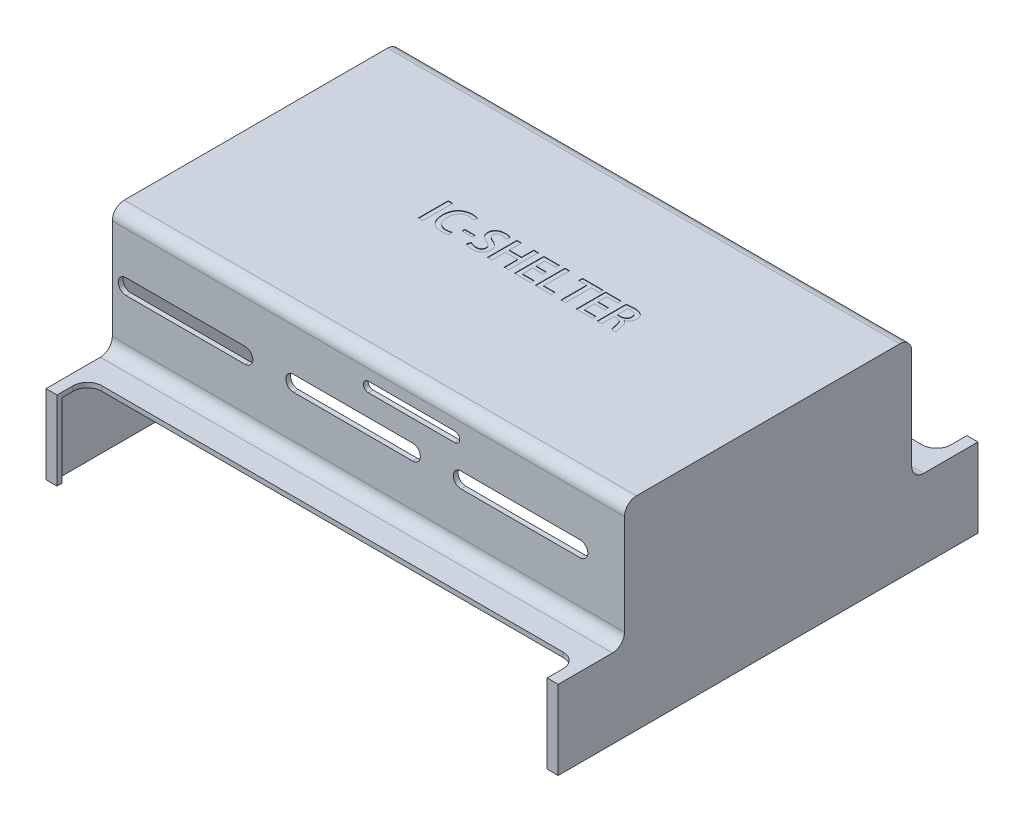
from build123d import *

# Parameters (mm, degrees)
BOSS_EXTRUDE1_DEPTH = 53.5
SHELL4_T            = -1
FILLET2_R           = 2.5
FILLET3_R           = 2.5
FILLET4_R           = 2.5
FILLET5_R           = 2.5
CUT_EXTRUDE9_DEPTH  = 74.85
LPATTERN4_COUNT     = 3
LPATTERN4_PITCH     = 35
SKETCH17_W          = 105
SKETCH17_H          = 58
BOSS_EXTRUDE2_DEPTH = 2
CUT_EXTRUDE8_DEPTH  = 74.85
CUT_EXTRUDE15_DEPTH = 17.5
SKETCH21_W          = 0.952687977
SKETCH21_H          = 6.208888889
SKETCH21_W_2        = 2.23016722
SKETCH21_H_2        = 0.591324006
CUT_EXTRUDE17_DEPTH = 0.1


with BuildPart() as part:
    # Sketch1 → Boss-Extrude1 (new body, symmetric)
    with BuildSketch(Plane(origin=(0, 0, 0), x_dir=(0, 0, -1), z_dir=(1, 0, 0))):
        Polygon((-43.85, 0), (-43.85, 16.5), (-30, 16.5), (-30, 42.428582774), (30, 42.428582774), (30, 16.5), (43.85, 16.5), (43.85, 0), align=None)
    extrude(amount=BOSS_EXTRUDE1_DEPTH, both=True)

    # Shell4
    shell4_openings = [part.faces().sort_by_distance(p)[0] for p in [
        (0, 0, 0),
    ]]
    offset(amount=SHELL4_T, openings=shell4_openings, kind=Kind.INTERSECTION)

    # Fillet2
    fillet2_edges = [part.edges().sort_by_distance(p)[0] for p in [
        (0, 42.428582774, 30),
    ]]
    fillet(fillet2_edges, radius=FILLET2_R)

    # Fillet3
    fillet3_edges = [part.edges().sort_by_distance(p)[0] for p in [
        (0, 16.5, 30),
    ]]
    fillet(fillet3_edges, radius=FILLET3_R)

    # Fillet4
    fillet4_edges = [part.edges().sort_by_distance(p)[0] for p in [
        (0, 42.428582774, -30),
    ]]
    fillet(fillet4_edges, radius=FILLET4_R)

    # Fillet5
    fillet5_edges = [part.edges().sort_by_distance(p)[0] for p in [
        (0, 16.5, -30),
    ]]
    fillet(fillet5_edges, radius=FILLET5_R)

    # Sketch16 → Cut-Extrude9 (cut, through all)
    with BuildSketch(Plane.XY.offset(30)):
        with BuildLine():
            Line((-50.64618597, 31.08095788), (-25.769711707, 31.08095788))
            ThreePointArc((-25.769711707, 31.08095788), (-24.153045214, 29.464291387), (-25.769711707, 27.847624894))
            Line((-25.769711707, 27.847624894), (-50.64618597, 27.847624894))
            ThreePointArc((-50.64618597, 27.847624894), (-52.262852463, 29.464291387), (-50.64618597, 31.08095788))
        make_face()
    cut_extrude9 = extrude(amount=-CUT_EXTRUDE9_DEPTH, mode=Mode.SUBTRACT)

    # LPattern4: Cut-Extrude9 ×3
    with Locations(*[(i * LPATTERN4_PITCH, 0, 0) for i in range(1, LPATTERN4_COUNT)]):
        add(cut_extrude9, mode=Mode.SUBTRACT)

    # Sketch17 → Boss-Extrude2 (add)
    with BuildSketch(Plane.XZ.offset(-41.428582774)):
        Rectangle(SKETCH17_W, SKETCH17_H)
    extrude(amount=BOSS_EXTRUDE2_DEPTH)

    # Sketch15 → Cut-Extrude8 (cut, through all)
    with BuildSketch(Plane(origin=(0, 0, -30), x_dir=(-1, 0, 0), z_dir=(0, 0, -1))):
        with BuildLine():
            Line((0, 37.667214373), (-18.032020922, 37.667214373))
            ThreePointArc((-18.032020922, 37.667214373), (-19.077355469, 36.621879827), (-18.032020922, 35.57654528))
            Line((-18.032020922, 35.57654528), (0, 35.57654528))
            ThreePointArc((0, 35.57654528), (1.045334546, 36.621879827), (0, 37.667214373))
        make_face()
    extrude(amount=-CUT_EXTRUDE8_DEPTH, mode=Mode.SUBTRACT)

    # Sketch19 → Cut-Extrude15 (cut, through all)
    with BuildSketch(Plane(origin=(0, 16.5, 0), x_dir=(1, 0, 0), z_dir=(0, 1, 0))):
        with BuildLine():
            Line((-48.19, -37.5), (48.19, -37.5))
            ThreePointArc((48.19, -37.5), (50.311320344, -38.378679656), (51.19, -40.5))
            Line((51.19, -40.5), (51.19, -43.85))
            Line((51.19, -43.85), (-51.19, -43.85))
            Line((-51.19, -43.85), (-51.19, -40.5))
            ThreePointArc((-51.19, -40.5), (-50.311320344, -38.378679656), (-48.19, -37.5))
        make_face()
    cut_extrude15 = extrude(amount=-CUT_EXTRUDE15_DEPTH, mode=Mode.SUBTRACT)

    # Mirror3: Cut-Extrude15 across plane
    add(cut_extrude15.mirror(Plane.XY), mode=Mode.SUBTRACT)

    # Sketch21 → Cut-Extrude17 (cut)
    with BuildSketch(Plane(origin=(0, 42.428582774, 0), x_dir=(1, 0, 0), z_dir=(0, 1, 0))):
        with Locations((-19.072509342, 3.116177041)):
            Rectangle(SKETCH21_W, SKETCH21_H)
        with BuildLine():
            add(Edge.make_bspline(
                [(-13.448639907, 0.959167257), (-13.484931771, 0.942766153), (-13.559790632, 0.908935761), (-13.680632958, 0.867309499), (-13.81173933, 0.829651537), (-14.002926186, 0.787850022), (-14.255990468, 0.748993456), (-14.462992266, 0.742472844), (-14.568364996, 0.739153576)],
                knots=[0, 0, 0, 0, 0.000119421, 0.000246328, 0.000382992, 0.000528448, 0.000833254, 0.001149288, 0.001149288, 0.001149288, 0.001149288], degree=3))
            add(Edge.make_bspline(
                [(-14.568364996, 0.739153576), (-14.647064082, 0.741274948), (-14.800721446, 0.745416859), (-15.024772836, 0.774975125), (-15.235473302, 0.824010073), (-15.432960619, 0.892314712), (-15.617241853, 0.979442608), (-15.788379173, 1.085791621), (-15.947001833, 1.210573556), (-16.089981709, 1.356127041), (-16.219668683, 1.517824022), (-16.331561149, 1.698100652), (-16.426760352, 1.894684388), (-16.504023858, 2.108771755), (-16.564698295, 2.339324727), (-16.608632391, 2.586519192), (-16.637588977, 2.850348429), (-16.641729264, 3.032014631), (-16.643861306, 3.125563691)],
                knots=[0, 0, 0, 0, 0.000236061, 0.000460902, 0.000676619, 0.000884034, 0.001086611, 0.00128684, 0.001487299, 0.001690558, 0.001897611, 0.002107912, 0.002325678, 0.002551715, 0.00278963, 0.003040016, 0.00330433, 0.003584938, 0.003584938, 0.003584938, 0.003584938], degree=3))
            add(Edge.make_bspline(
                [(-16.643861306, 3.125563691), (-16.640943543, 3.223813584), (-16.635279976, 3.41452297), (-16.604235026, 3.690926626), (-16.557400874, 3.949079282), (-16.489898056, 4.187334094), (-16.408395866, 4.408140842), (-16.307485436, 4.609366238), (-16.188335309, 4.791778463), (-16.051615132, 4.954078939), (-15.900995778, 5.096659144), (-15.740950975, 5.222927234), (-15.568311996, 5.327379025), (-15.38550063, 5.413603661), (-15.191927611, 5.480569082), (-14.988006165, 5.528777818), (-14.773320171, 5.557236345), (-14.626722929, 5.560671565), (-14.551939361, 5.562423971)],
                knots=[0, 0, 0, 0, 0.000294771, 0.000572169, 0.000833577, 0.00108096, 0.001314129, 0.0015387, 0.001754774, 0.001966286, 0.002173751, 0.002376056, 0.00257667, 0.002777684, 0.002981389, 0.003189986, 0.003405367, 0.003629656, 0.003629656, 0.003629656, 0.003629656], degree=3))
            add(Edge.make_bspline(
                [(-14.551939361, 5.562423971), (-14.495595257, 5.561493678), (-14.385884084, 5.559682247), (-14.22607526, 5.546500742), (-14.075493938, 5.526005166), (-13.934883595, 5.495824676), (-13.803127722, 5.462425921), (-13.681777175, 5.423178834), (-13.569002305, 5.383146396), (-13.499304019, 5.350597529), (-13.465500931, 5.3348116)],
                knots=[0, 0, 0, 0, 0.000169015, 0.000329099, 0.000480754, 0.000624568, 0.000760306, 0.000888321, 0.001007104, 0.001118965, 0.001118965, 0.001118965, 0.001118965], degree=3))
            Line((-13.465500931, 5.3348116), (-13.26211683, 6.072733482))
            add(Edge.make_bspline(
                [(-13.26211683, 6.072733482), (-13.287516924, 6.084472583), (-13.345719737, 6.111372038), (-13.448005369, 6.146675398), (-13.575528755, 6.182379663), (-13.727350945, 6.220252334), (-13.905267656, 6.254675462), (-14.109071611, 6.279507243), (-14.338541368, 6.295879506), (-14.499894256, 6.298844333), (-14.584790631, 6.300404287)],
                knots=[0, 0, 0, 0, 8.3906e-05, 0.000192266, 0.000324095, 0.000481171, 0.000661571, 0.000867344, 0.001096718, 0.001351413, 0.001351413, 0.001351413, 0.001351413], degree=3))
            add(Edge.make_bspline(
                [(-14.584790631, 6.300404287), (-14.692070043, 6.298039653), (-14.902269638, 6.293406471), (-15.210163122, 6.253671989), (-15.502793439, 6.189611606), (-15.780864215, 6.100197426), (-16.043314754, 5.984718225), (-16.291421401, 5.844633185), (-16.523606253, 5.677974436), (-16.739807675, 5.486844957), (-16.936295284, 5.270792944), (-17.109250661, 5.029556216), (-17.254558948, 4.762783315), (-17.374154905, 4.472199149), (-17.469310143, 4.157847942), (-17.538865341, 3.819367045), (-17.583762903, 3.456386387), (-17.592976856, 3.206258427), (-17.597721396, 3.077460046)],
                knots=[0, 0, 0, 0, 0.000321732, 0.000630391, 0.000929574, 0.00121935, 0.001505137, 0.001788331, 0.002072565, 0.00236097, 0.002652508, 0.002946834, 0.003249281, 0.003561729, 0.003887965, 0.004233119, 0.004597223, 0.00498374, 0.00498374, 0.00498374, 0.00498374], degree=3))
            add(Edge.make_bspline(
                [(-17.597721396, 3.077460046), (-17.594607757, 2.95570403), (-17.588553518, 2.718958541), (-17.547006002, 2.374790653), (-17.486574273, 2.051873889), (-17.400449442, 1.750238073), (-17.291560154, 1.470402896), (-17.160047896, 1.210830042), (-17.002834037, 0.974228859), (-16.824503049, 0.758378197), (-16.624345002, 0.567471026), (-16.407607878, 0.399150093), (-16.172672674, 0.257923536), (-15.920693867, 0.142351461), (-15.651616968, 0.051983291), (-15.365195294, -0.013546689), (-15.061472706, -0.053743054), (-14.853199323, -0.060103606), (-14.746700462, -0.063356021)],
                knots=[0, 0, 0, 0, 0.000365202, 0.000710109, 0.001038693, 0.001349892, 0.001649689, 0.001938285, 0.002221062, 0.002500172, 0.002776497, 0.003049188, 0.003321832, 0.003596918, 0.003879264, 0.004171839, 0.004477157, 0.004796648, 0.004796648, 0.004796648, 0.004796648], degree=3))
            add(Edge.make_bspline(
                [(-14.746700462, -0.063356021), (-14.664535645, -0.06229573), (-14.505900216, -0.06024863), (-14.276198, -0.042744618), (-14.063019774, -0.019303427), (-13.867232787, 0.014632151), (-13.691420521, 0.05590092), (-13.536032251, 0.098543787), (-13.402696754, 0.144399673), (-13.323676458, 0.18125297), (-13.287165465, 0.19828088)],
                knots=[0, 0, 0, 0, 0.000246454, 0.000475829, 0.000690779, 0.000889646, 0.001071505, 0.001232344, 0.001372983, 0.001493778, 0.001493778, 0.001493778, 0.001493778], degree=3))
            Line((-13.287165465, 0.19828088), (-13.448639907, 0.959167257))
        make_face()
        with Locations((-11.52610274, 2.477923795)):
            Rectangle(SKETCH21_W_2, SKETCH21_H_2)
        with BuildLine():
            add(Edge.make_bspline(
                [(-6.36450849, 6.034694205), (-6.400841142, 6.05133698), (-6.477467403, 6.086436912), (-6.603017076, 6.133215137), (-6.744432258, 6.177279263), (-6.901641854, 6.218385532), (-7.074125694, 6.254026059), (-7.26191422, 6.279032433), (-7.464769546, 6.295762964), (-7.605033788, 6.29881876), (-7.677811109, 6.300404287)],
                knots=[0, 0, 0, 0, 0.000119859, 0.000252785, 0.000401585, 0.000564076, 0.0007401, 0.000929588, 0.001132056, 0.001350396, 0.001350396, 0.001350396, 0.001350396], degree=3))
            add(Edge.make_bspline(
                [(-7.677811109, 6.300404287), (-7.754521336, 6.297853766), (-7.903981852, 6.292884388), (-8.121657479, 6.269468304), (-8.326819618, 6.232048901), (-8.51937854, 6.181030522), (-8.699211888, 6.114878735), (-8.866661323, 6.034928747), (-9.021764159, 5.941317518), (-9.163060094, 5.834043122), (-9.28987772, 5.71587521), (-9.400584066, 5.587457298), (-9.495512791, 5.450449424), (-9.573554103, 5.303648541), (-9.634822452, 5.14737203), (-9.677309785, 4.981763859), (-9.707187696, 4.807896244), (-9.711307388, 4.688476585), (-9.71341659, 4.627336035)],
                knots=[0, 0, 0, 0, 0.000230201, 0.000448519, 0.00065609, 0.000855309, 0.001045363, 0.001230083, 0.001411176, 0.001587871, 0.001761359, 0.001930231, 0.002095557, 0.002260365, 0.002427911, 0.002597807, 0.00277256, 0.002955893, 0.002955893, 0.002955893, 0.002955893], degree=3))
            add(Edge.make_bspline(
                [(-9.71341659, 4.627336035), (-9.711094258, 4.575655827), (-9.706519361, 4.473848042), (-9.685875056, 4.324299214), (-9.649746431, 4.181702562), (-9.603194525, 4.044105126), (-9.541740067, 3.913261005), (-9.469028709, 3.787852774), (-9.382084589, 3.669835462), (-9.283605616, 3.557543467), (-9.173794204, 3.450967899), (-9.055449535, 3.34861466), (-8.926847231, 3.252430814), (-8.789520428, 3.161194354), (-8.643614898, 3.073991851), (-8.48839947, 2.992096337), (-8.324613444, 2.914344164), (-8.210721277, 2.868431181), (-8.152981264, 2.845154636)],
                knots=[0, 0, 0, 0, 0.000155154, 0.000305648, 0.00045191, 0.000595873, 0.00074075, 0.000884827, 0.001030089, 0.001179752, 0.001332411, 0.001488811, 0.001648844, 0.001813824, 0.001983245, 0.002158544, 0.002340138, 0.002526867, 0.002526867, 0.002526867, 0.002526867], degree=3))
            add(Edge.make_bspline(
                [(-8.152981264, 2.845154636), (-8.107836032, 2.82637643), (-8.020363738, 2.789992238), (-7.895471777, 2.730548433), (-7.779572657, 2.671518151), (-7.673025676, 2.610068476), (-7.575968684, 2.546925671), (-7.48771214, 2.482896668), (-7.40951946, 2.416384289), (-7.339806285, 2.348741513), (-7.279575649, 2.277195376), (-7.226000568, 2.203827524), (-7.182985159, 2.12523145), (-7.14563632, 2.044559456), (-7.11925346, 1.958740472), (-7.098741116, 1.870249517), (-7.088538268, 1.777337774), (-7.087181551, 1.714543257), (-7.086488248, 1.682454329)],
                knots=[0, 0, 0, 0, 0.000146662, 0.000284169, 0.000414828, 0.000536779, 0.000652956, 0.000762075, 0.000863628, 0.000960697, 0.001053087, 0.001143922, 0.001232696, 0.001321445, 0.001410126, 0.001501497, 0.001593618, 0.00168989, 0.00168989, 0.00168989, 0.00168989], degree=3))
            add(Edge.make_bspline(
                [(-7.086488248, 1.682454329), (-7.087878434, 1.647613237), (-7.09059194, 1.579606862), (-7.104076172, 1.480228215), (-7.129600297, 1.38700758), (-7.162164195, 1.298242907), (-7.20451278, 1.214663096), (-7.256459403, 1.136642187), (-7.318337404, 1.06463771), (-7.388486587, 0.997960532), (-7.467451029, 0.937292903), (-7.556067927, 0.886538908), (-7.651761639, 0.840956865), (-7.756218278, 0.805237654), (-7.868561577, 0.777273391), (-7.988852215, 0.755908584), (-8.117534854, 0.743452756), (-8.206143912, 0.740609878), (-8.251535074, 0.739153576)],
                knots=[0, 0, 0, 0, 0.000104585, 0.000204139, 0.000300045, 0.000393972, 0.00048737, 0.000580435, 0.000674479, 0.000771577, 0.000870368, 0.000972387, 0.00107736, 0.001187933, 0.001302894, 0.001424416, 0.001554118, 0.001690343, 0.001690343, 0.001690343, 0.001690343], degree=3))
            add(Edge.make_bspline(
                [(-8.251535074, 0.739153576), (-8.316114191, 0.741052376), (-8.444000229, 0.74481257), (-8.633375537, 0.765086853), (-8.818169898, 0.797541577), (-8.996267079, 0.844158542), (-9.166833228, 0.896649146), (-9.32501799, 0.959534354), (-9.471966821, 1.026724849), (-9.562449536, 1.07945307), (-9.606649963, 1.105210584)],
                knots=[0, 0, 0, 0, 0.000193762, 0.000383707, 0.000570815, 0.000756064, 0.000935661, 0.00110582, 0.001266432, 0.00141982, 0.00141982, 0.00141982, 0.00141982], degree=3))
            Line((-9.606649963, 1.105210584), (-9.817670563, 0.313326779))
            add(Edge.make_bspline(
                [(-9.817670563, 0.313326779), (-9.775230117, 0.286920751), (-9.685939197, 0.231364819), (-9.533583195, 0.163668539), (-9.360876813, 0.100161219), (-9.16854353, 0.045400816), (-8.963324899, -0.000920073), (-8.750372284, -0.036708122), (-8.531585981, -0.057907762), (-8.383767069, -0.061526343), (-8.309024797, -0.063356021)],
                knots=[0, 0, 0, 0, 0.000149797, 0.00031516, 0.000498898, 0.000701638, 0.000914542, 0.001129799, 0.001349045, 0.001573288, 0.001573288, 0.001573288, 0.001573288], degree=3))
            add(Edge.make_bspline(
                [(-8.309024797, -0.063356021), (-8.223302387, -0.060628864), (-8.056529536, -0.055323184), (-7.814222984, -0.027947251), (-7.587367385, 0.01359945), (-7.376432416, 0.070888625), (-7.180878886, 0.143712036), (-7.001421327, 0.232954735), (-6.836748975, 0.336246807), (-6.689630971, 0.455399557), (-6.559542187, 0.587185213), (-6.445194631, 0.728056458), (-6.348019375, 0.878116743), (-6.268892722, 1.037528462), (-6.207935972, 1.206575006), (-6.163377256, 1.384165585), (-6.135636403, 1.570911233), (-6.132090238, 1.698392035), (-6.130281639, 1.763409245)],
                knots=[0, 0, 0, 0, 0.000257212, 0.000500405, 0.00073075, 0.00094849, 0.001155293, 0.001355728, 0.001548746, 0.001737295, 0.001922302, 0.002103338, 0.002280702, 0.002457526, 0.00263605, 0.002818736, 0.003006065, 0.003201052, 0.003201052, 0.003201052, 0.003201052], degree=3))
            add(Edge.make_bspline(
                [(-6.130281639, 1.763409245), (-6.130832734, 1.815483545), (-6.131913482, 1.917605933), (-6.150770182, 2.067370692), (-6.178551848, 2.211460026), (-6.217811168, 2.349617132), (-6.270757234, 2.480927489), (-6.332316287, 2.607430171), (-6.407936384, 2.726685525), (-6.494328617, 2.84050525), (-6.593029493, 2.948587051), (-6.701738955, 3.054799044), (-6.824640921, 3.155216459), (-6.95866148, 3.252645789), (-7.104132976, 3.346701442), (-7.26262932, 3.435520564), (-7.431952958, 3.522849086), (-7.551187184, 3.575172862), (-7.612108569, 3.601907106)],
                knots=[0, 0, 0, 0, 0.000156114, 0.000306154, 0.000452035, 0.000596112, 0.000736202, 0.000876297, 0.001017577, 0.001159075, 0.00130445, 0.001456291, 0.001614625, 0.001780071, 0.001953205, 0.002133948, 0.002324945, 0.002524485, 0.002524485, 0.002524485, 0.002524485], degree=3))
            add(Edge.make_bspline(
                [(-7.612108569, 3.601907106), (-7.659989925, 3.621863732), (-7.753260789, 3.660738398), (-7.886359403, 3.723680606), (-8.011284301, 3.783692284), (-8.124969457, 3.846008441), (-8.22876604, 3.908734168), (-8.32366158, 3.970139142), (-8.408442009, 4.032258768), (-8.483407379, 4.095221165), (-8.550348939, 4.159525234), (-8.606455544, 4.229502769), (-8.655465988, 4.302372528), (-8.694431678, 4.380454911), (-8.723485486, 4.463006077), (-8.744681336, 4.549432256), (-8.758160592, 4.639815049), (-8.759086749, 4.701594532), (-8.7595565, 4.732929403)],
                knots=[0, 0, 0, 0, 0.000155597, 0.000303097, 0.000441621, 0.000571308, 0.000691834, 0.000805404, 0.000910298, 0.001006891, 0.001098982, 0.001188219, 0.001275428, 0.001362003, 0.001449212, 0.001537425, 0.001628683, 0.00172261, 0.00172261, 0.00172261, 0.00172261], degree=3))
            add(Edge.make_bspline(
                [(-8.7595565, 4.732929403), (-8.757118933, 4.784107228), (-8.752254333, 4.886241703), (-8.703977996, 5.035126623), (-8.622858496, 5.174140993), (-8.532053172, 5.280881753), (-8.443145124, 5.358174327), (-8.364924072, 5.409874781), (-8.277476812, 5.454438575), (-8.180891399, 5.492075267), (-8.07471918, 5.521340533), (-7.958726566, 5.541492444), (-7.833872997, 5.557560928), (-7.747087768, 5.56077223), (-7.702449561, 5.562423971)],
                knots=[0, 0, 0, 0, 0.000153172, 0.000305682, 0.000463868, 0.00063363, 0.000723475, 0.00081654, 0.00091414, 0.001017413, 0.001127005, 0.001243907, 0.001370369, 0.001504306, 0.001504306, 0.001504306, 0.001504306], degree=3))
            add(Edge.make_bspline(
                [(-7.702449561, 5.562423971), (-7.63983033, 5.560486699), (-7.518228966, 5.556724678), (-7.34291989, 5.53816945), (-7.180655496, 5.50870526), (-7.032634509, 5.470298975), (-6.899598304, 5.425486089), (-6.782269774, 5.379805473), (-6.680655859, 5.334960901), (-6.620488829, 5.30120956), (-6.592545938, 5.285534695)],
                knots=[0, 0, 0, 0, 0.000187901, 0.000364888, 0.000528279, 0.000682231, 0.000823218, 0.000949151, 0.001059942, 0.001156013, 0.001156013, 0.001156013, 0.001156013], degree=3))
            Line((-6.592545938, 5.285534695), (-6.36450849, 6.034694205))
        make_face()
        Polygon((-0.725075606, 6.237312937), (-1.677763582, 6.237312937), (-1.677763582, 3.674648058), (-4.254239468, 3.674648058), (-4.254239468, 6.237312937), (-5.206927445, 6.237312937), (-5.206927445, 0.0358841), (-4.254239468, 0.0358841), (-4.254239468, 2.858059346), (-1.677763582, 2.858059346), (-1.677763582, 0.0358841), (-0.725075606, 0.0358841), align=None)
        Polygon((3.893514833, 0.74443439), (1.452495439, 0.74443439), (1.452495439, 2.85981809), (3.625894766, 2.85981809), (3.625894766, 3.597800698), (1.452495439, 3.597800698), (1.452495439, 5.412829929), (3.75564995, 5.412829929), (3.75564995, 6.150812537), (0.499807462, 6.150812537), (0.499807462, 0.006451782), (3.893514833, 0.006451782), align=None)
        Polygon((8.199996436, 0.814242193), (5.807635236, 0.814242193), (5.807635236, 6.223411414), (4.85494726, 6.223411414), (4.85494726, 0.011732596), (8.199996436, 0.011732596), align=None)
        Polygon((12.817634747, 6.220795641), (8.515641091, 6.220795641), (8.515641091, 5.417935442), (10.186239081, 5.417935442), (10.186239081, 0.016875919), (11.138927058, 0.016875919), (11.138927058, 5.417935442), (12.817634747, 5.417935442), align=None)
        Polygon((16.808756991, 0.74443439), (14.367737597, 0.74443439), (14.367737597, 2.85981809), (16.541136925, 2.85981809), (16.541136925, 3.597800698), (14.367737597, 3.597800698), (14.367737597, 5.412829929), (16.670892108, 5.412829929), (16.670892108, 6.150812537), (13.415049621, 6.150812537), (13.415049621, 0.006451782), (16.808756991, 0.006451782), align=None)
        with BuildLine():
            add(Edge.make_bspline(
                [(20.452987377, 2.954488915), (20.492496859, 2.969062855), (20.570928431, 2.997994063), (20.683369082, 3.051757594), (20.792231589, 3.110033753), (20.895108773, 3.176657995), (20.991872812, 3.251420882), (21.083586992, 3.332563067), (21.170527087, 3.420490365), (21.251572831, 3.51557182), (21.325579013, 3.617188229), (21.390084097, 3.725671521), (21.446471312, 3.840162411), (21.489465268, 3.962379126), (21.527353776, 4.089661608), (21.551680465, 4.22388675), (21.570705719, 4.364006852), (21.57359585, 4.459881801), (21.575071589, 4.508836811)],
                knots=[0, 0, 0, 0, 0.00012627, 0.000250664, 0.000373515, 0.000496528, 0.000617851, 0.000740034, 0.00086365, 0.00098849, 0.001114516, 0.001240274, 0.001366736, 0.001496645, 0.001628474, 0.001764693, 0.001905416, 0.002052242, 0.002052242, 0.002052242, 0.002052242], degree=3))
            add(Edge.make_bspline(
                [(21.575071589, 4.508836811), (21.573625127, 4.571507911), (21.570792801, 4.694224645), (21.544833292, 4.872728692), (21.507290388, 5.041786612), (21.451611644, 5.19983564), (21.380682438, 5.347693958), (21.29483491, 5.485931885), (21.192472583, 5.613365836), (21.113675463, 5.688789381), (21.074089721, 5.726680321)],
                knots=[0, 0, 0, 0, 0.000187901, 0.000367931, 0.000540116, 0.000706723, 0.000869401, 0.0010312, 0.001193911, 0.001358176, 0.001358176, 0.001358176, 0.001358176], degree=3))
            add(Edge.make_bspline(
                [(21.074089721, 5.726680321), (21.023892757, 5.768022032), (20.922051038, 5.85189784), (20.746196628, 5.953089031), (20.553021498, 6.040368714), (20.339824064, 6.110487766), (20.107034956, 6.162369524), (19.855340497, 6.199680646), (19.583639488, 6.220860931), (19.395974703, 6.221477244), (19.29894788, 6.221795891)],
                knots=[0, 0, 0, 0, 0.000194793, 0.000395204, 0.0006063, 0.000830023, 0.001067109, 0.001320978, 0.001592822, 0.001883829, 0.001883829, 0.001883829, 0.001883829], degree=3))
            add(Edge.make_bspline(
                [(19.29894788, 6.221795891), (19.159686823, 6.219406862), (18.885211349, 6.214698224), (18.546363177, 6.192585006), (18.286714567, 6.164857463), (18.104242944, 6.144578043), (17.932945591, 6.119827858), (17.822557119, 6.100795167), (17.769017304, 6.09156407)],
                knots=[0, 0, 0, 0, 0.000417814, 0.000823487, 0.0010181, 0.001201177, 0.001374236, 0.001537222, 0.001537222, 0.001537222, 0.001537222], degree=3))
            Line((17.769017304, 6.09156407), (17.770189418, 0.005251024))
            Line((17.770189418, 0.005251024), (18.722877395, 0.005251024))
            Line((18.722877395, 0.005251024), (18.722877395, 2.632793495))
            Line((18.722877395, 2.632793495), (19.291498139, 2.632793495))
            add(Edge.make_bspline(
                [(19.291498139, 2.632793495), (19.33078166, 2.632293374), (19.407054167, 2.631322343), (19.518078527, 2.618762835), (19.622790397, 2.600978329), (19.720583635, 2.573082743), (19.810598365, 2.534629672), (19.894189591, 2.48955045), (19.969968319, 2.434384597), (20.04042421, 2.371854979), (20.103857371, 2.297962753), (20.162630004, 2.214188131), (20.216570518, 2.119824954), (20.26574057, 2.014446098), (20.311354726, 1.898517195), (20.352200082, 1.771493557), (20.388400288, 1.633895679), (20.40885491, 1.538234135), (20.41941084, 1.488866488)],
                knots=[0, 0, 0, 0, 0.000117789, 0.000228697, 0.000334792, 0.000436161, 0.000532911, 0.000627952, 0.000720424, 0.000813475, 0.000909939, 0.001011824, 0.001120095, 0.001235558, 0.001360399, 0.001493599, 0.001635607, 0.001787043, 0.001787043, 0.001787043, 0.001787043], degree=3))
            add(Edge.make_bspline(
                [(20.41941084, 1.488866488), (20.438262932, 1.396894097), (20.474415218, 1.220520449), (20.531228441, 0.968447212), (20.584279251, 0.739705172), (20.637228491, 0.536541682), (20.685573872, 0.360737402), (20.730196563, 0.214323839), (20.769529697, 0.09822242), (20.798777792, 0.032699902), (20.811279561, 0.004693039)],
                knots=[0, 0, 0, 0, 0.000281646, 0.000540107, 0.000775172, 0.000986036, 0.001169923, 0.001322086, 0.001445284, 0.001537255, 0.001537255, 0.001537255, 0.001537255], degree=3))
            Line((20.811279561, 0.004693039), (21.795205575, 0.005251024))
            add(Edge.make_bspline(
                [(21.795205575, 0.005251024), (21.778759881, 0.040817479), (21.741379042, 0.121659543), (21.693067305, 0.263476557), (21.63891456, 0.436614243), (21.584223672, 0.641020967), (21.524439027, 0.871682473), (21.463344472, 1.126360988), (21.395572141, 1.401674506), (21.351508415, 1.592835093), (21.328687063, 1.691840406)],
                knots=[0, 0, 0, 0, 0.000117485, 0.000267043, 0.000448879, 0.000661783, 0.000901671, 0.001163752, 0.001447462, 0.001752261, 0.001752261, 0.001752261, 0.001752261], degree=3))
            add(Edge.make_bspline(
                [(21.328687063, 1.691840406), (21.310183107, 1.770852886), (21.27449349, 1.923248685), (21.199596412, 2.137171804), (21.114625888, 2.329883084), (21.01637898, 2.500728745), (20.90184625, 2.648958756), (20.769085045, 2.771993544), (20.619457185, 2.87255521), (20.508376139, 2.916710029), (20.45226211, 2.939015408)],
                knots=[0, 0, 0, 0, 0.000243298, 0.000469262, 0.000678807, 0.0008744, 0.001059109, 0.00123843, 0.001415452, 0.001596169, 0.001596169, 0.001596169, 0.001596169], degree=3))
            Line((20.45226211, 2.939015408), (20.452987377, 2.954488915))
        make_face()
        with BuildLine():
            Line((18.722877395, 3.299206118), (18.722877395, 5.435070303))
            add(Edge.make_bspline(
                [(18.722877395, 5.435070303), (18.739252007, 5.439420365), (18.774465012, 5.448775014), (18.832970217, 5.458919794), (18.900685934, 5.468073994), (18.9781132, 5.476513569), (19.065039258, 5.481830025), (19.161642396, 5.486530003), (19.26763288, 5.490305234), (19.341572696, 5.490667392), (19.379902795, 5.490855133)],
                knots=[0, 0, 0, 0, 5.0807e-05, 0.000109258, 0.000177952, 0.000255821, 0.00034284, 0.000439162, 0.000545987, 0.000660972, 0.000660972, 0.000660972, 0.000660972], degree=3))
            add(Edge.make_bspline(
                [(19.379902795, 5.490855133), (19.422546979, 5.490579048), (19.505992526, 5.49003881), (19.62872552, 5.480673388), (19.746036193, 5.463323189), (19.858231436, 5.43737381), (19.965418244, 5.40338215), (20.067287357, 5.36103789), (20.164205732, 5.31184364), (20.254902706, 5.254199174), (20.339368113, 5.187931326), (20.411872065, 5.10837497), (20.475183605, 5.019280281), (20.527234288, 4.918684011), (20.565846345, 4.806467024), (20.597361544, 4.684655768), (20.615180639, 4.551550509), (20.619928917, 4.459213545), (20.622384758, 4.41145626)],
                knots=[0, 0, 0, 0, 0.000127907, 0.000250286, 0.000368925, 0.000483334, 0.000595391, 0.000705858, 0.000813951, 0.000921033, 0.001027858, 0.001134959, 0.001242708, 0.001355004, 0.001473387, 0.001598023, 0.001731924, 0.001875369, 0.001875369, 0.001875369, 0.001875369], degree=3))
            add(Edge.make_bspline(
                [(20.622384758, 4.41145626), (20.62071617, 4.370342645), (20.617445567, 4.289755734), (20.601157661, 4.172177138), (20.574031387, 4.060932975), (20.536702096, 3.95609927), (20.488164118, 3.858377959), (20.430217029, 3.766921031), (20.36156236, 3.682090127), (20.283164098, 3.603529894), (20.195019598, 3.533091772), (20.098459665, 3.47203337), (19.994091918, 3.420336381), (19.882551696, 3.376270502), (19.761870334, 3.344191817), (19.633661156, 3.319781904), (19.497681935, 3.30251858), (19.404205049, 3.30032636), (19.356437602, 3.299206118)],
                knots=[0, 0, 0, 0, 0.000123393, 0.000241863, 0.000355403, 0.000466368, 0.000574981, 0.000682063, 0.000790538, 0.000901707, 0.001014395, 0.001128316, 0.001243749, 0.001363364, 0.001487464, 0.001617701, 0.001754787, 0.001898044, 0.001898044, 0.001898044, 0.001898044], degree=3))
            Line((19.356437602, 3.299206118), (18.722877395, 3.299206118))
        make_face(mode=Mode.SUBTRACT)
    extrude(amount=-CUT_EXTRUDE17_DEPTH, mode=Mode.SUBTRACT)


solid = part.part
